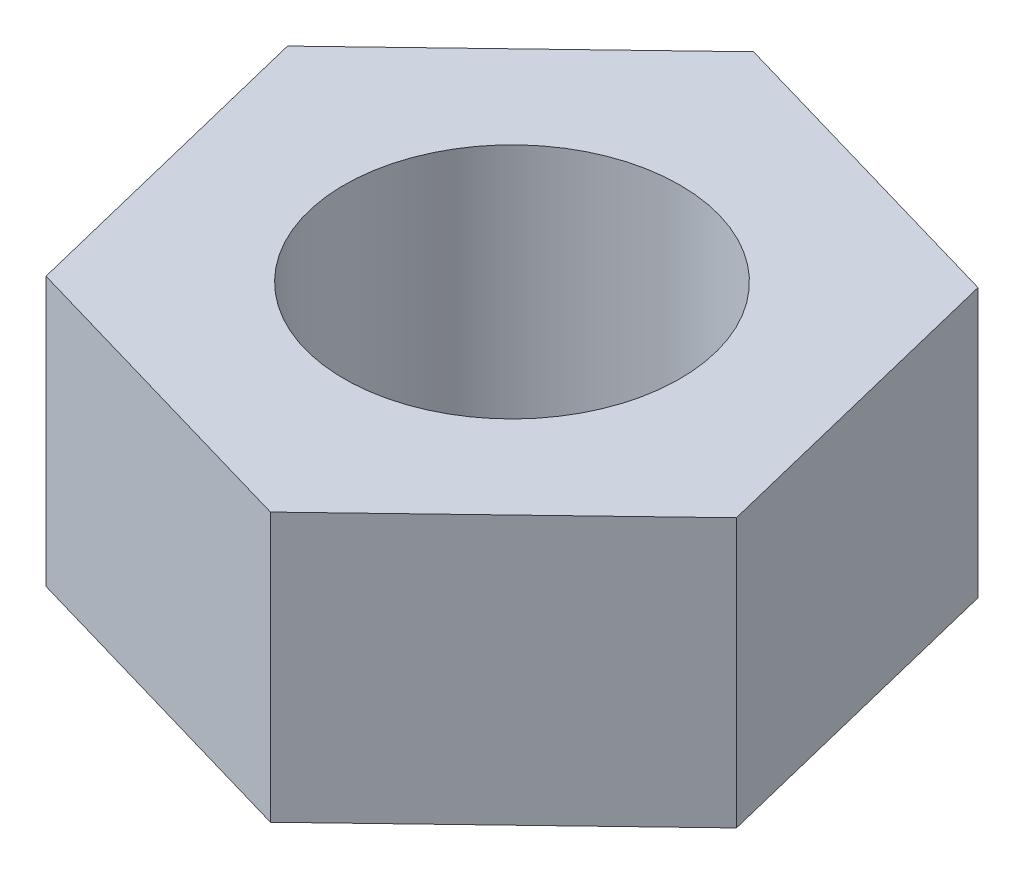
from build123d import *

# Parameters (mm, degrees)
DODANIE_WYCI_GNI_CIE1_DEPTH = 8
SZKIC2_R                    = 5
WYTNIJ_WYCI_GNI_CIE1_DEPTH  = 9


with BuildPart() as part:
    # Szkic1 → Dodanie-wyciągnięcie1 (new body)
    with BuildSketch(Plane(origin=(0, 0, 0), x_dir=(1, 0, 0), z_dir=(0, 1, 0))):
        Polygon((-2.338764127, 9.532235608), (-9.424540255, 2.740688657), (-7.085776128, -6.791546952), (2.338764127, -9.532235608), (9.424540255, -2.740688657), (7.085776128, 6.791546952), align=None)
    extrude(amount=DODANIE_WYCI_GNI_CIE1_DEPTH)

    # Szkic2 → Wytnij-wyciągnięcie1 (cut, through all)
    with BuildSketch(Plane(origin=(0, 0, 0), x_dir=(-1, 0, 0), z_dir=(0, -1, 0))):
        Circle(SZKIC2_R)
    extrude(amount=-WYTNIJ_WYCI_GNI_CIE1_DEPTH, mode=Mode.SUBTRACT)


solid = part.part
